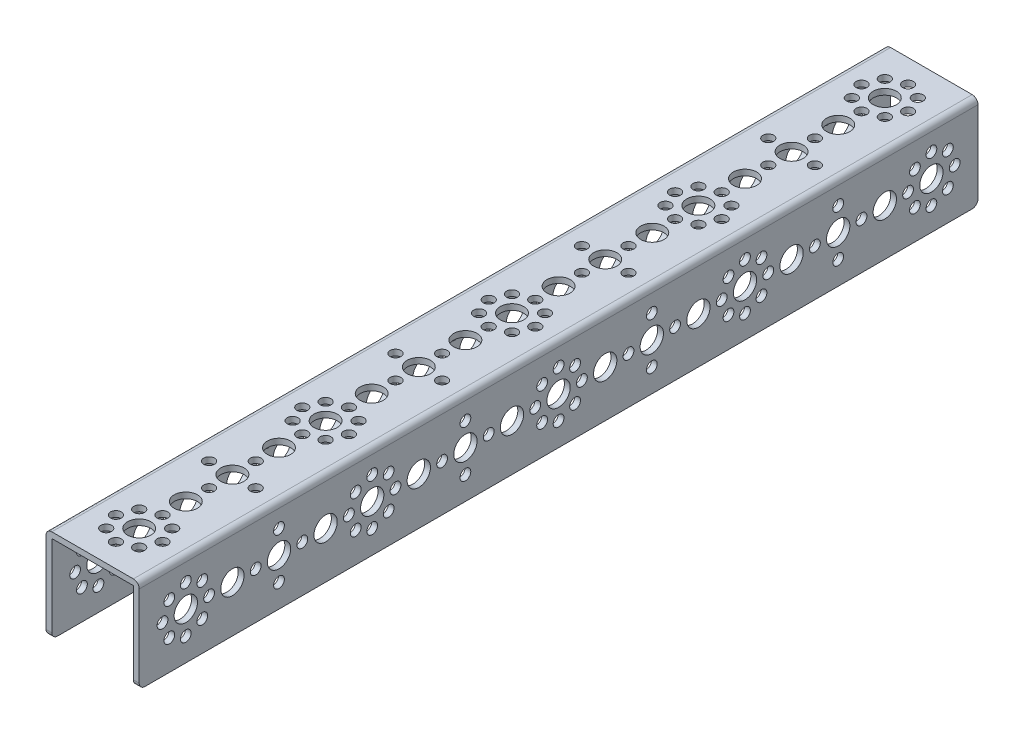
from build123d import *

# Parameters (mm, degrees)
BOSS_EXTRUDE1_DEPTH = 288
SKETCH2_R           = 4
SKETCH2_R_2         = 1.85
CUT_EXTRUDE1_DEPTH  = 33
SKETCH3_R           = 4
SKETCH3_R_2         = 1.85
CUT_EXTRUDE2_DEPTH  = 33
FILLET1_R           = 2


with BuildPart() as part:
    # Sketch1 → Boss-Extrude1 (new body)
    with BuildSketch(Plane.XY):
        Polygon((14, -16), (16, -16), (16, 16), (-16, 16), (-16, -16), (-14, -16), (-14, 14), (14, 14), align=None)
    extrude(amount=-BOSS_EXTRUDE1_DEPTH)

    # Sketch2 → Cut-Extrude1 (cut, through all)
    with BuildSketch(Plane(origin=(0, 16, 0), x_dir=(1, 0, 0), z_dir=(0, 1, 0))):
        with Locations((0, 256)):
            Circle(SKETCH2_R)
        with Locations((0, 224)):
            Circle(SKETCH2_R)
        with Locations((0.175415159, 192)):
            Circle(SKETCH2_R)
        with Locations((0, 160)):
            Circle(SKETCH2_R)
        with Locations((0, 240)):
            Circle(SKETCH2_R)
        with Locations((0, 232)):
            Circle(SKETCH2_R_2)
        with Locations((0, 248)):
            Circle(SKETCH2_R_2)
        with Locations((-8, 240)):
            Circle(SKETCH2_R_2)
        with Locations((8, 240)):
            Circle(SKETCH2_R_2)
        with Locations((0, 264)):
            Circle(SKETCH2_R_2)
        with Locations((-8, 272)):
            Circle(SKETCH2_R_2)
        with Locations((0, 272)):
            Circle(SKETCH2_R)
        with Locations((8, 272)):
            Circle(SKETCH2_R_2)
        with Locations((5.66, 277.66)):
            Circle(SKETCH2_R_2)
        with Locations((-5.66, 277.66)):
            Circle(SKETCH2_R_2)
        with Locations((0, 280)):
            Circle(SKETCH2_R_2)
        with Locations((5.66, 266.34)):
            Circle(SKETCH2_R_2)
        with Locations((-5.66, 266.34)):
            Circle(SKETCH2_R_2)
        with Locations((0, 176)):
            Circle(SKETCH2_R)
        with Locations((0, 168)):
            Circle(SKETCH2_R_2)
        with Locations((0, 184)):
            Circle(SKETCH2_R_2)
        with Locations((-8, 176)):
            Circle(SKETCH2_R_2)
        with Locations((8, 176)):
            Circle(SKETCH2_R_2)
        with Locations((0, 200)):
            Circle(SKETCH2_R_2)
        with Locations((-8, 208)):
            Circle(SKETCH2_R_2)
        with Locations((0, 208)):
            Circle(SKETCH2_R)
        with Locations((8, 208)):
            Circle(SKETCH2_R_2)
        with Locations((5.66, 213.66)):
            Circle(SKETCH2_R_2)
        with Locations((-5.66, 213.66)):
            Circle(SKETCH2_R_2)
        with Locations((0, 216)):
            Circle(SKETCH2_R_2)
        with Locations((5.66, 202.34)):
            Circle(SKETCH2_R_2)
        with Locations((-5.66, 202.34)):
            Circle(SKETCH2_R_2)
        with Locations((0, 32)):
            Circle(SKETCH2_R)
        with Locations((0, 64)):
            Circle(SKETCH2_R)
        with Locations((-0.175415159, 96)):
            Circle(SKETCH2_R)
        with Locations((0, 128)):
            Circle(SKETCH2_R)
        with Locations((0, 48)):
            Circle(SKETCH2_R)
        with Locations((0, 56)):
            Circle(SKETCH2_R_2)
        with Locations((0, 40)):
            Circle(SKETCH2_R_2)
        with Locations((8, 48)):
            Circle(SKETCH2_R_2)
        with Locations((-8, 48)):
            Circle(SKETCH2_R_2)
        with Locations((0, 24)):
            Circle(SKETCH2_R_2)
        with Locations((8, 16)):
            Circle(SKETCH2_R_2)
        with Locations((0, 16)):
            Circle(SKETCH2_R)
        with Locations((-8, 16)):
            Circle(SKETCH2_R_2)
        with Locations((-5.66, 10.34)):
            Circle(SKETCH2_R_2)
        with Locations((5.66, 10.34)):
            Circle(SKETCH2_R_2)
        with Locations((0, 8)):
            Circle(SKETCH2_R_2)
        with Locations((-5.66, 21.66)):
            Circle(SKETCH2_R_2)
        with Locations((5.66, 21.66)):
            Circle(SKETCH2_R_2)
        with Locations((0, 112)):
            Circle(SKETCH2_R)
        with Locations((0, 120)):
            Circle(SKETCH2_R_2)
        with Locations((0, 104)):
            Circle(SKETCH2_R_2)
        with Locations((8, 112)):
            Circle(SKETCH2_R_2)
        with Locations((-8, 112)):
            Circle(SKETCH2_R_2)
        with Locations((0, 88)):
            Circle(SKETCH2_R_2)
        with Locations((8, 80)):
            Circle(SKETCH2_R_2)
        with Locations((0, 80)):
            Circle(SKETCH2_R)
        with Locations((-8, 80)):
            Circle(SKETCH2_R_2)
        with Locations((-5.66, 74.34)):
            Circle(SKETCH2_R_2)
        with Locations((5.66, 74.34)):
            Circle(SKETCH2_R_2)
        with Locations((0, 72)):
            Circle(SKETCH2_R_2)
        with Locations((-5.66, 85.66)):
            Circle(SKETCH2_R_2)
        with Locations((5.66, 85.66)):
            Circle(SKETCH2_R_2)
        with Locations((0, 136)):
            Circle(SKETCH2_R_2)
        with Locations((-8, 144)):
            Circle(SKETCH2_R_2)
        with Locations((0, 144)):
            Circle(SKETCH2_R)
        with Locations((8, 144)):
            Circle(SKETCH2_R_2)
        with Locations((5.66, 149.66)):
            Circle(SKETCH2_R_2)
        with Locations((-5.66, 149.66)):
            Circle(SKETCH2_R_2)
        with Locations((0, 152)):
            Circle(SKETCH2_R_2)
        with Locations((5.66, 138.34)):
            Circle(SKETCH2_R_2)
        with Locations((-5.66, 138.34)):
            Circle(SKETCH2_R_2)
    extrude(amount=-CUT_EXTRUDE1_DEPTH, mode=Mode.SUBTRACT)

    # Sketch3 → Cut-Extrude2 (cut, through all)
    with BuildSketch(Plane(origin=(16, 0, 0), x_dir=(0, 0, -1), z_dir=(1, 0, 0))):
        with Locations((32, 0)):
            Circle(SKETCH3_R)
        with Locations((64, 0)):
            Circle(SKETCH3_R)
        with Locations((96, 0.175415159)):
            Circle(SKETCH3_R)
        with Locations((128, 0)):
            Circle(SKETCH3_R)
        with Locations((48, 0)):
            Circle(SKETCH3_R)
        with Locations((56, 0)):
            Circle(SKETCH3_R_2)
        with Locations((40, 0)):
            Circle(SKETCH3_R_2)
        with Locations((48, -8)):
            Circle(SKETCH3_R_2)
        with Locations((48, 8)):
            Circle(SKETCH3_R_2)
        with Locations((24, 0)):
            Circle(SKETCH3_R_2)
        with Locations((16, -8)):
            Circle(SKETCH3_R_2)
        with Locations((16, 0)):
            Circle(SKETCH3_R)
        with Locations((16, 8)):
            Circle(SKETCH3_R_2)
        with Locations((10.34, 5.66)):
            Circle(SKETCH3_R_2)
        with Locations((10.34, -5.66)):
            Circle(SKETCH3_R_2)
        with Locations((8, 0)):
            Circle(SKETCH3_R_2)
        with Locations((21.66, 5.66)):
            Circle(SKETCH3_R_2)
        with Locations((21.66, -5.66)):
            Circle(SKETCH3_R_2)
        with Locations((112, 0)):
            Circle(SKETCH3_R)
        with Locations((120, 0)):
            Circle(SKETCH3_R_2)
        with Locations((104, 0)):
            Circle(SKETCH3_R_2)
        with Locations((112, -8)):
            Circle(SKETCH3_R_2)
        with Locations((112, 8)):
            Circle(SKETCH3_R_2)
        with Locations((88, 0)):
            Circle(SKETCH3_R_2)
        with Locations((80, -8)):
            Circle(SKETCH3_R_2)
        with Locations((80, 0)):
            Circle(SKETCH3_R)
        with Locations((80, 8)):
            Circle(SKETCH3_R_2)
        with Locations((74.34, 5.66)):
            Circle(SKETCH3_R_2)
        with Locations((74.34, -5.66)):
            Circle(SKETCH3_R_2)
        with Locations((72, 0)):
            Circle(SKETCH3_R_2)
        with Locations((85.66, 5.66)):
            Circle(SKETCH3_R_2)
        with Locations((85.66, -5.66)):
            Circle(SKETCH3_R_2)
        with Locations((256, 0)):
            Circle(SKETCH3_R)
        with Locations((224, 0)):
            Circle(SKETCH3_R)
        with Locations((192, -0.175415159)):
            Circle(SKETCH3_R)
        with Locations((160, 0)):
            Circle(SKETCH3_R)
        with Locations((240, 0)):
            Circle(SKETCH3_R)
        with Locations((232, 0)):
            Circle(SKETCH3_R_2)
        with Locations((248, 0)):
            Circle(SKETCH3_R_2)
        with Locations((240, 8)):
            Circle(SKETCH3_R_2)
        with Locations((240, -8)):
            Circle(SKETCH3_R_2)
        with Locations((264, 0)):
            Circle(SKETCH3_R_2)
        with Locations((272, 8)):
            Circle(SKETCH3_R_2)
        with Locations((272, 0)):
            Circle(SKETCH3_R)
        with Locations((272, -8)):
            Circle(SKETCH3_R_2)
        with Locations((277.66, -5.66)):
            Circle(SKETCH3_R_2)
        with Locations((277.66, 5.66)):
            Circle(SKETCH3_R_2)
        with Locations((280, 0)):
            Circle(SKETCH3_R_2)
        with Locations((266.34, -5.66)):
            Circle(SKETCH3_R_2)
        with Locations((266.34, 5.66)):
            Circle(SKETCH3_R_2)
        with Locations((176, 0)):
            Circle(SKETCH3_R)
        with Locations((168, 0)):
            Circle(SKETCH3_R_2)
        with Locations((184, 0)):
            Circle(SKETCH3_R_2)
        with Locations((176, 8)):
            Circle(SKETCH3_R_2)
        with Locations((176, -8)):
            Circle(SKETCH3_R_2)
        with Locations((200, 0)):
            Circle(SKETCH3_R_2)
        with Locations((208, 8)):
            Circle(SKETCH3_R_2)
        with Locations((208, 0)):
            Circle(SKETCH3_R)
        with Locations((208, -8)):
            Circle(SKETCH3_R_2)
        with Locations((213.66, -5.66)):
            Circle(SKETCH3_R_2)
        with Locations((213.66, 5.66)):
            Circle(SKETCH3_R_2)
        with Locations((216, 0)):
            Circle(SKETCH3_R_2)
        with Locations((202.34, -5.66)):
            Circle(SKETCH3_R_2)
        with Locations((202.34, 5.66)):
            Circle(SKETCH3_R_2)
        with Locations((152, 0)):
            Circle(SKETCH3_R_2)
        with Locations((144, -8)):
            Circle(SKETCH3_R_2)
        with Locations((144, 0)):
            Circle(SKETCH3_R)
        with Locations((144, 8)):
            Circle(SKETCH3_R_2)
        with Locations((138.34, 5.66)):
            Circle(SKETCH3_R_2)
        with Locations((138.34, -5.66)):
            Circle(SKETCH3_R_2)
        with Locations((136, 0)):
            Circle(SKETCH3_R_2)
        with Locations((149.66, 5.66)):
            Circle(SKETCH3_R_2)
        with Locations((149.66, -5.66)):
            Circle(SKETCH3_R_2)
    extrude(amount=-CUT_EXTRUDE2_DEPTH, mode=Mode.SUBTRACT)

    # Fillet1
    fillet1_edges = [part.edges().sort_by_distance(p)[0] for p in [
        (-15, -16, -288),
        (-16, 16, -144),
        (16, 16, -144),
        (15, -16, -288),
        (15, -16, 0),
        (-15, -16, 0),
    ]]
    fillet(fillet1_edges, radius=FILLET1_R)


solid = part.part
